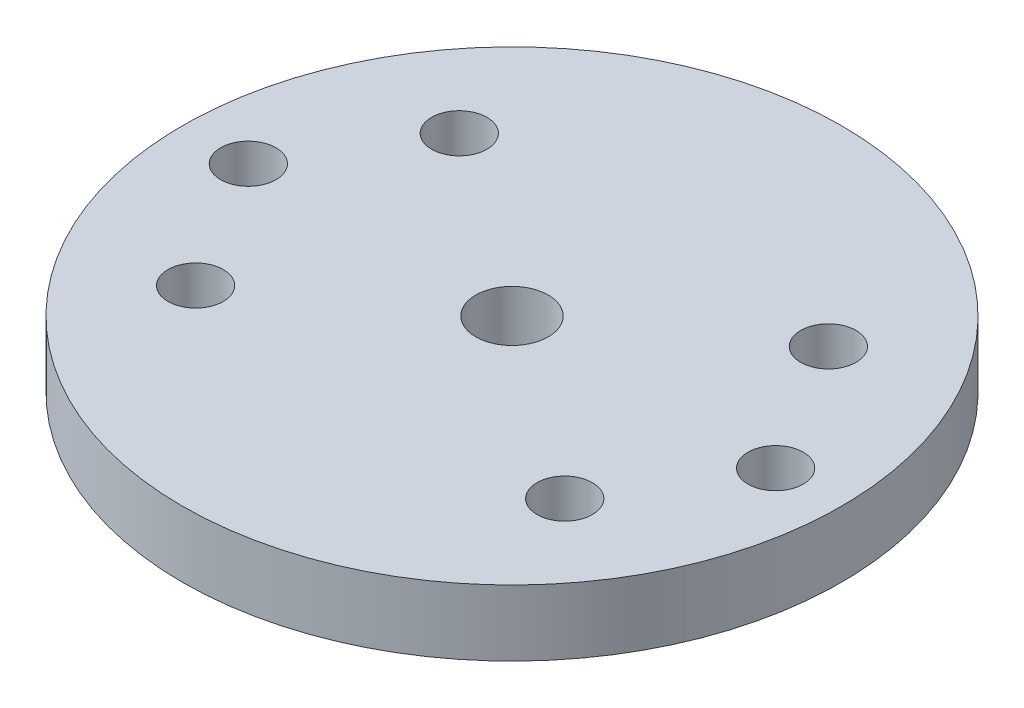
from build123d import *

# Parameters (mm, degrees)
SKETCH1_R           = 31.75
SKETCH1_R_2         = 3.4925
BOSS_EXTRUDE1_DEPTH = 3.175
SKETCH2_R           = 2.667
CUT_EXTRUDE1_DEPTH  = 7.35


with BuildPart() as part:
    # Sketch1 → Boss-Extrude1 (new body, symmetric)
    with BuildSketch(Plane(origin=(0, 0, 0), x_dir=(1, 0, 0), z_dir=(0, 1, 0))):
        Circle(SKETCH1_R)
        Circle(SKETCH1_R_2, mode=Mode.SUBTRACT)
    extrude(amount=BOSS_EXTRUDE1_DEPTH, both=True)

    # Sketch2 → Cut-Extrude1 (cut, through all)
    with BuildSketch(Plane.XZ.offset(3.175)):
        with Locations((-17.78, 12.7)):
            Circle(SKETCH2_R)
        with Locations((-25.4, 0)):
            Circle(SKETCH2_R)
        with Locations((-17.78, -12.7)):
            Circle(SKETCH2_R)
        with Locations((17.78, -12.7)):
            Circle(SKETCH2_R)
        with Locations((25.4, 0)):
            Circle(SKETCH2_R)
        with Locations((17.78, 12.7)):
            Circle(SKETCH2_R)
    extrude(amount=-CUT_EXTRUDE1_DEPTH, mode=Mode.SUBTRACT)


solid = part.part
